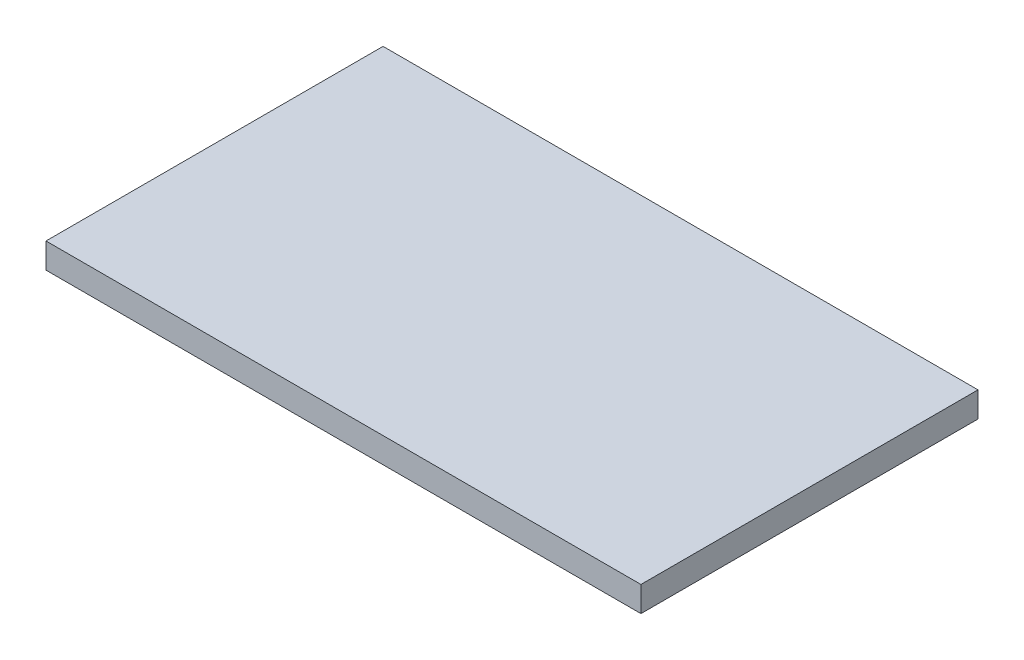
from build123d import *

# Parameters (mm, degrees)
SKETCH1_W           = 70.6
SKETCH1_H           = 40
BOSS_EXTRUDE1_DEPTH = 3


with BuildPart() as part:
    # Sketch1 → Boss-Extrude1 (new body)
    with BuildSketch(Plane(origin=(0, 0, 0), x_dir=(1, 0, 0), z_dir=(0, 1, 0))):
        with Locations((-1.581990899, 0.143817354)):
            Rectangle(SKETCH1_W, SKETCH1_H)
    extrude(amount=BOSS_EXTRUDE1_DEPTH)


solid = part.part
